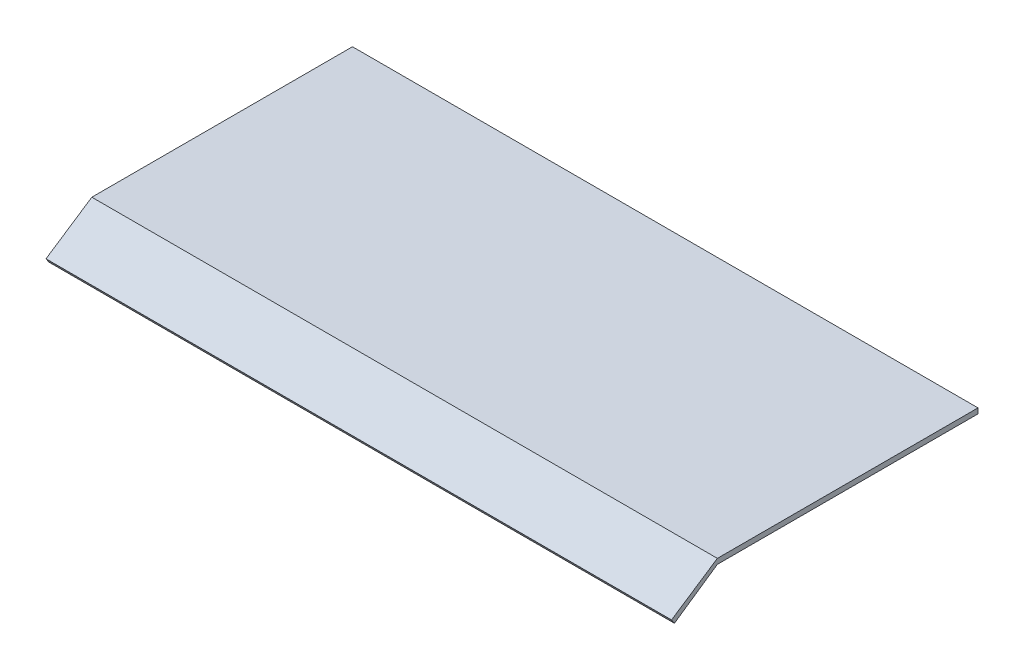
from build123d import *

# Parameters (mm, degrees)
BOSS_EXTRUDE1_DEPTH = 304.8


with BuildPart() as part:
    # Sketch1 → Boss-Extrude1 (new body)
    with BuildSketch(Plane(origin=(0, 0, 0), x_dir=(0, 0, -1), z_dir=(1, 0, 0))):
        Polygon((0, 0), (127, 0), (127, -2.54), (0, -2.54), (-20.928214549, -16.933395562), (-22.33090694, -14.819774048), align=None)
    extrude(amount=BOSS_EXTRUDE1_DEPTH)


solid = part.part
